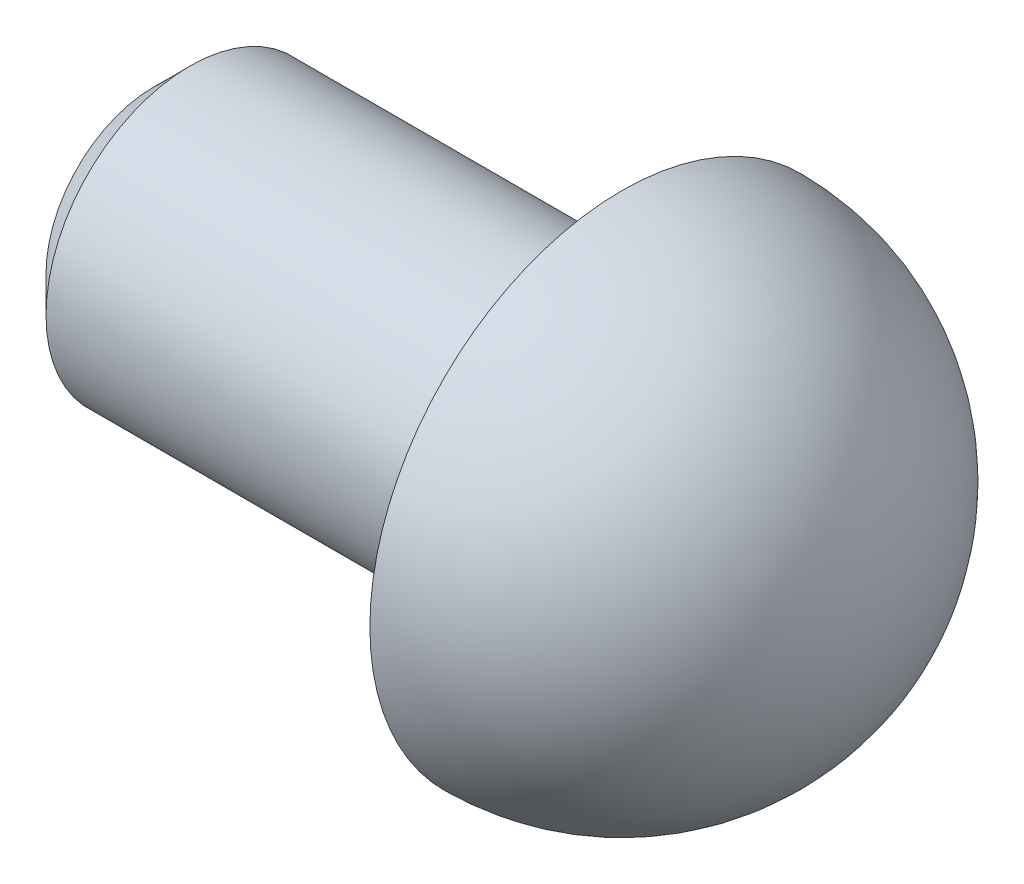
from build123d import *

# Parameters (mm, degrees)
CHAMFER1_SIZE = 0.5


with BuildPart() as part:
    # Sketch1 → Revolve1 (revolve)
    with BuildSketch(Plane.XY):
        with BuildLine():
            Line((-6.5, 0), (-6.5, 2))
            Line((-6.5, 2), (0, 2))
            Line((0, 2), (0, 3.5))
            ThreePointArc((0, 3.5), (2.474873734, 2.474873734), (3.5, 0))
            Line((3.5, 0), (-6.5, 0))
        make_face()
    revolve(axis=Axis((-6.5, 0, 0), (1, 0, 0)))

    # Chamfer1
    chamfer1_edges = [part.edges().sort_by_distance(p)[0] for p in [
        (-6.5, -2, 0),
    ]]
    chamfer(chamfer1_edges, length=CHAMFER1_SIZE)


solid = part.part
